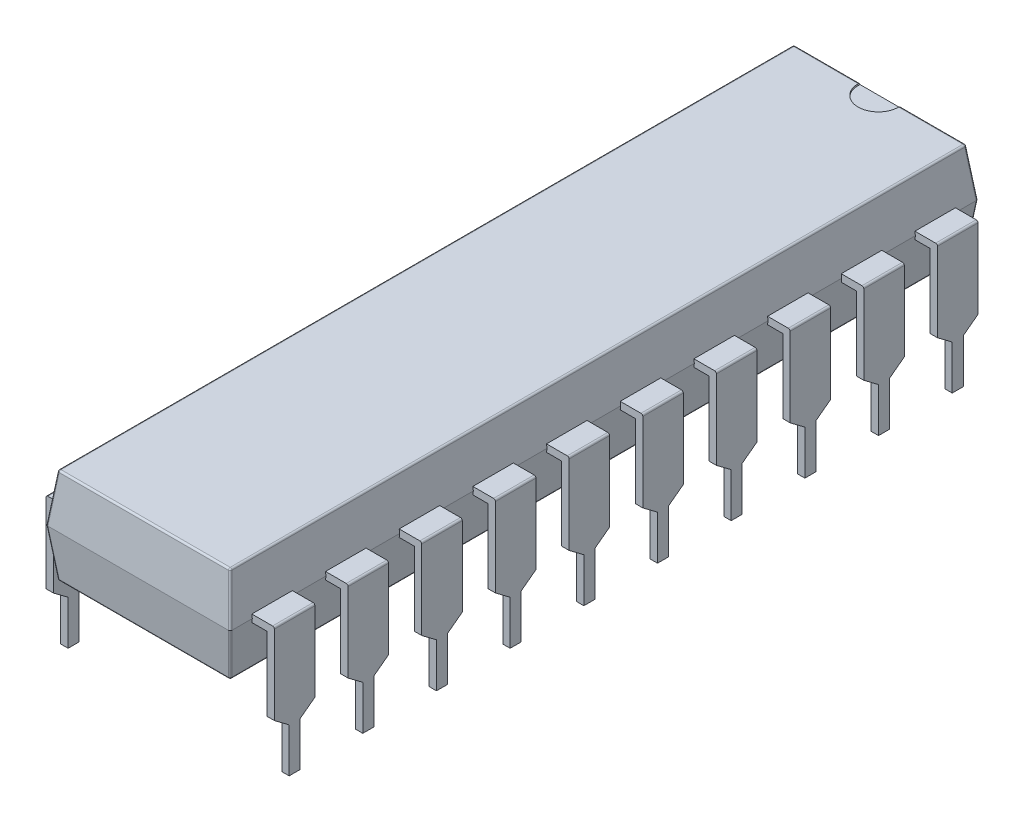
from build123d import *

# Parameters (mm, degrees)
SKETCH1_W                = 6.35
SKETCH1_H                = 25.781
EXTRUDE1_DEPTH           = 1.651
EXTRUDE1_TAPER           = 7
EXTRUDE1_OTHER_WAY_DEPTH = 1.651
EXTRUDE1_OTHER_WAY_TAPER = 7
SKETCH2_W                = 0.790734928
SKETCH2_H                = 1.397
EXTRUDE6_DEPTH           = 0.127
SKETCH7_W                = 0.254
SKETCH7_H                = 1.397
EXTRUDE7_DEPTH           = 4.699
FILLET2_R                = 0.0635
SKETCH6_R                = 0.6985
CUT_EXTRUDE2_DEPTH       = 0.05576
CUT_EXTRUDE3_DEPTH       = 16.415859469
LPATTERN8_COUNT          = 5
LPATTERN8_PITCH          = 2.54
LPATTERN8_COUNT_DIR2     = 6
LPATTERN8_PITCH_DIR2     = 2.54
FILLET6_R                = 0.0635
MIRROR1_COPY_1_SKETCH_W  = 0.790734928
MIRROR1_COPY_1_SKETCH_H  = 1.397
MIRROR1_COPY_1_DEPTH     = 0.127
MIRROR1_COPY_2_SKETCH_W  = 0.790734928
MIRROR1_COPY_2_SKETCH_H  = 1.397
MIRROR1_COPY_2_DEPTH     = 0.127
MIRROR1_COPY_3_SKETCH_W  = 0.790734928
MIRROR1_COPY_3_SKETCH_H  = 1.397
MIRROR1_COPY_3_DEPTH     = 0.127
MIRROR1_COPY_4_SKETCH_W  = 0.790734928
MIRROR1_COPY_4_SKETCH_H  = 1.397
MIRROR1_COPY_4_DEPTH     = 0.127
MIRROR1_COPY_5_SKETCH_W  = 0.790734928
MIRROR1_COPY_5_SKETCH_H  = 1.397
MIRROR1_COPY_5_DEPTH     = 0.127
MIRROR1_COPY_6_SKETCH_W  = 0.790734928
MIRROR1_COPY_6_SKETCH_H  = 1.397
MIRROR1_COPY_6_DEPTH     = 0.127
MIRROR1_COPY_7_SKETCH_W  = 0.790734928
MIRROR1_COPY_7_SKETCH_H  = 1.397
MIRROR1_COPY_7_DEPTH     = 0.127
MIRROR1_COPY_8_SKETCH_W  = 0.790734928
MIRROR1_COPY_8_SKETCH_H  = 1.397
MIRROR1_COPY_8_DEPTH     = 0.127
MIRROR1_COPY_9_SKETCH_W  = 0.790734928
MIRROR1_COPY_9_SKETCH_H  = 1.397
MIRROR1_COPY_9_DEPTH     = 0.127
MIRROR1_COPY_10_SKETCH_W = 0.790734928
MIRROR1_COPY_10_SKETCH_H = 1.397
MIRROR1_COPY_10_DEPTH    = 0.127
MIRROR1_COPY_11_SKETCH_W = 0.790734928
MIRROR1_COPY_11_SKETCH_H = 1.397
MIRROR1_COPY_11_DEPTH    = 0.127
MIRROR1_COPY_12_SKETCH_W = 0.790734928
MIRROR1_COPY_12_SKETCH_H = 1.397
MIRROR1_COPY_12_DEPTH    = 0.127
MIRROR1_COPY_13_SKETCH_W = 0.790734928
MIRROR1_COPY_13_SKETCH_H = 1.397
MIRROR1_COPY_13_DEPTH    = 0.127
MIRROR1_COPY_14_SKETCH_W = 0.790734928
MIRROR1_COPY_14_SKETCH_H = 1.397
MIRROR1_COPY_14_DEPTH    = 0.127
MIRROR1_COPY_15_SKETCH_W = 0.790734928
MIRROR1_COPY_15_SKETCH_H = 1.397
MIRROR1_COPY_15_DEPTH    = 0.127
MIRROR1_COPY_16_SKETCH_W = 0.790734928
MIRROR1_COPY_16_SKETCH_H = 1.397
MIRROR1_COPY_16_DEPTH    = 0.127
MIRROR1_COPY_17_SKETCH_W = 0.790734928
MIRROR1_COPY_17_SKETCH_H = 1.397
MIRROR1_COPY_17_DEPTH    = 0.127
MIRROR1_COPY_18_SKETCH_W = 0.790734928
MIRROR1_COPY_18_SKETCH_H = 1.397
MIRROR1_COPY_18_DEPTH    = 0.127
MIRROR1_COPY_19_SKETCH_W = 0.790734928
MIRROR1_COPY_19_SKETCH_H = 1.397
MIRROR1_COPY_19_DEPTH    = 0.127
MIRROR1_COPY_20_SKETCH_W = 0.790734928
MIRROR1_COPY_20_SKETCH_H = 1.397
MIRROR1_COPY_20_DEPTH    = 0.127
MIRROR1_COPY_21_SKETCH_W = 0.790734928
MIRROR1_COPY_21_SKETCH_H = 1.397
MIRROR1_COPY_21_DEPTH    = 0.127
MIRROR1_COPY_22_SKETCH_W = 0.790734928
MIRROR1_COPY_22_SKETCH_H = 1.397
MIRROR1_COPY_22_DEPTH    = 0.127
MIRROR1_COPY_23_SKETCH_W = 0.790734928
MIRROR1_COPY_23_SKETCH_H = 1.397
MIRROR1_COPY_23_DEPTH    = 0.127
MIRROR1_COPY_24_SKETCH_W = 0.790734928
MIRROR1_COPY_24_SKETCH_H = 1.397
MIRROR1_COPY_24_DEPTH    = 0.127
MIRROR1_COPY_25_SKETCH_W = 0.790734928
MIRROR1_COPY_25_SKETCH_H = 1.397
MIRROR1_COPY_25_DEPTH    = 0.127
MIRROR1_COPY_26_SKETCH_W = 0.790734928
MIRROR1_COPY_26_SKETCH_H = 1.397
MIRROR1_COPY_26_DEPTH    = 0.127
MIRROR1_COPY_27_SKETCH_W = 0.790734928
MIRROR1_COPY_27_SKETCH_H = 1.397
MIRROR1_COPY_27_DEPTH    = 0.127
MIRROR1_COPY_28_SKETCH_W = 0.790734928
MIRROR1_COPY_28_SKETCH_H = 1.397
MIRROR1_COPY_28_DEPTH    = 0.127
MIRROR1_COPY_29_SKETCH_W = 0.790734928
MIRROR1_COPY_29_SKETCH_H = 1.397
MIRROR1_COPY_29_DEPTH    = 0.127
MIRROR1_COPY_30_SKETCH_W = 0.254
MIRROR1_COPY_30_SKETCH_H = 1.397
MIRROR1_COPY_30_DEPTH    = 4.699
MIRROR1_COPY_31_SKETCH_W = 0.254
MIRROR1_COPY_31_SKETCH_H = 1.397
MIRROR1_COPY_31_DEPTH    = 4.699
MIRROR1_COPY_32_SKETCH_W = 0.254
MIRROR1_COPY_32_SKETCH_H = 1.397
MIRROR1_COPY_32_DEPTH    = 4.699
MIRROR1_COPY_33_SKETCH_W = 0.254
MIRROR1_COPY_33_SKETCH_H = 1.397
MIRROR1_COPY_33_DEPTH    = 4.699
MIRROR1_COPY_34_SKETCH_W = 0.254
MIRROR1_COPY_34_SKETCH_H = 1.397
MIRROR1_COPY_34_DEPTH    = 4.699
MIRROR1_COPY_35_SKETCH_W = 0.254
MIRROR1_COPY_35_SKETCH_H = 1.397
MIRROR1_COPY_35_DEPTH    = 4.699
MIRROR1_COPY_36_SKETCH_W = 0.254
MIRROR1_COPY_36_SKETCH_H = 1.397
MIRROR1_COPY_36_DEPTH    = 4.699
MIRROR1_COPY_37_SKETCH_W = 0.254
MIRROR1_COPY_37_SKETCH_H = 1.397
MIRROR1_COPY_37_DEPTH    = 4.699
MIRROR1_COPY_38_SKETCH_W = 0.254
MIRROR1_COPY_38_SKETCH_H = 1.397
MIRROR1_COPY_38_DEPTH    = 4.699
MIRROR1_COPY_39_SKETCH_W = 0.254
MIRROR1_COPY_39_SKETCH_H = 1.397
MIRROR1_COPY_39_DEPTH    = 4.699
MIRROR1_COPY_40_SKETCH_W = 0.254
MIRROR1_COPY_40_SKETCH_H = 1.397
MIRROR1_COPY_40_DEPTH    = 4.699
MIRROR1_COPY_41_SKETCH_W = 0.254
MIRROR1_COPY_41_SKETCH_H = 1.397
MIRROR1_COPY_41_DEPTH    = 4.699
MIRROR1_COPY_42_SKETCH_W = 0.254
MIRROR1_COPY_42_SKETCH_H = 1.397
MIRROR1_COPY_42_DEPTH    = 4.699
MIRROR1_COPY_43_SKETCH_W = 0.254
MIRROR1_COPY_43_SKETCH_H = 1.397
MIRROR1_COPY_43_DEPTH    = 4.699
MIRROR1_COPY_44_SKETCH_W = 0.254
MIRROR1_COPY_44_SKETCH_H = 1.397
MIRROR1_COPY_44_DEPTH    = 4.699
MIRROR1_COPY_45_SKETCH_W = 0.254
MIRROR1_COPY_45_SKETCH_H = 1.397
MIRROR1_COPY_45_DEPTH    = 4.699
MIRROR1_COPY_46_SKETCH_W = 0.254
MIRROR1_COPY_46_SKETCH_H = 1.397
MIRROR1_COPY_46_DEPTH    = 4.699
MIRROR1_COPY_47_SKETCH_W = 0.254
MIRROR1_COPY_47_SKETCH_H = 1.397
MIRROR1_COPY_47_DEPTH    = 4.699
MIRROR1_COPY_48_SKETCH_W = 0.254
MIRROR1_COPY_48_SKETCH_H = 1.397
MIRROR1_COPY_48_DEPTH    = 4.699
MIRROR1_COPY_49_SKETCH_W = 0.254
MIRROR1_COPY_49_SKETCH_H = 1.397
MIRROR1_COPY_49_DEPTH    = 4.699
MIRROR1_COPY_50_SKETCH_W = 0.254
MIRROR1_COPY_50_SKETCH_H = 1.397
MIRROR1_COPY_50_DEPTH    = 4.699
MIRROR1_COPY_51_SKETCH_W = 0.254
MIRROR1_COPY_51_SKETCH_H = 1.397
MIRROR1_COPY_51_DEPTH    = 4.699
MIRROR1_COPY_52_SKETCH_W = 0.254
MIRROR1_COPY_52_SKETCH_H = 1.397
MIRROR1_COPY_52_DEPTH    = 4.699
MIRROR1_COPY_53_SKETCH_W = 0.254
MIRROR1_COPY_53_SKETCH_H = 1.397
MIRROR1_COPY_53_DEPTH    = 4.699
MIRROR1_COPY_54_SKETCH_W = 0.254
MIRROR1_COPY_54_SKETCH_H = 1.397
MIRROR1_COPY_54_DEPTH    = 4.699
MIRROR1_COPY_55_SKETCH_W = 0.254
MIRROR1_COPY_55_SKETCH_H = 1.397
MIRROR1_COPY_55_DEPTH    = 4.699
MIRROR1_COPY_56_SKETCH_W = 0.254
MIRROR1_COPY_56_SKETCH_H = 1.397
MIRROR1_COPY_56_DEPTH    = 4.699
MIRROR1_COPY_57_SKETCH_W = 0.254
MIRROR1_COPY_57_SKETCH_H = 1.397
MIRROR1_COPY_57_DEPTH    = 4.699
MIRROR1_COPY_58_SKETCH_W = 0.254
MIRROR1_COPY_58_SKETCH_H = 1.397
MIRROR1_COPY_58_DEPTH    = 4.699
MIRROR1_COPY_59_DEPTH    = 16.415859469
MIRROR1_COPY_60_DEPTH    = 16.415859469
MIRROR1_COPY_61_DEPTH    = 16.415859469
MIRROR1_COPY_62_DEPTH    = 16.415859469
MIRROR1_COPY_63_DEPTH    = 16.415859469
MIRROR1_COPY_64_DEPTH    = 16.415859469
MIRROR1_COPY_65_DEPTH    = 16.415859469
MIRROR1_COPY_66_DEPTH    = 16.415859469
MIRROR1_COPY_67_DEPTH    = 16.415859469
MIRROR1_COPY_68_DEPTH    = 16.415859469
MIRROR1_COPY_69_DEPTH    = 16.415859469
MIRROR1_COPY_70_DEPTH    = 16.415859469
MIRROR1_COPY_71_DEPTH    = 16.415859469
MIRROR1_COPY_72_DEPTH    = 16.415859469
MIRROR1_COPY_73_DEPTH    = 16.415859469
MIRROR1_COPY_74_DEPTH    = 16.415859469
MIRROR1_COPY_75_DEPTH    = 16.415859469
MIRROR1_COPY_76_DEPTH    = 16.415859469
MIRROR1_COPY_77_DEPTH    = 16.415859469
MIRROR1_COPY_78_DEPTH    = 16.415859469
MIRROR1_COPY_79_DEPTH    = 16.415859469
MIRROR1_COPY_80_DEPTH    = 16.415859469
MIRROR1_COPY_81_DEPTH    = 16.415859469
MIRROR1_COPY_82_DEPTH    = 16.415859469
MIRROR1_COPY_83_DEPTH    = 16.415859469
MIRROR1_COPY_84_DEPTH    = 16.415859469
MIRROR1_COPY_85_DEPTH    = 16.415859469
MIRROR1_COPY_86_DEPTH    = 16.415859469
MIRROR1_COPY_87_DEPTH    = 16.415859469
FILLET7_R                = 0.0635


with BuildPart() as part:
    # Sketch1 → Extrude1 (new body)
    with BuildSketch(Plane(origin=(0, 0, 0), x_dir=(1, 0, 0), z_dir=(0, 1, 0))):
        Rectangle(SKETCH1_W, SKETCH1_H)
    extrude(amount=EXTRUDE1_DEPTH, taper=EXTRUDE1_TAPER)

    # Sketch1 → Extrude1 other way (add)
    with BuildSketch(Plane(origin=(0, 0, 0), x_dir=(1, 0, 0), z_dir=(0, 1, 0))):
        Rectangle(SKETCH1_W, SKETCH1_H)
    extrude(amount=-EXTRUDE1_OTHER_WAY_DEPTH, taper=EXTRUDE1_OTHER_WAY_TAPER)

    # Sketch2 → Extrude6 (add, symmetric)
    with BuildSketch(Plane(origin=(0, 0, 0), x_dir=(1, 0, 0), z_dir=(0, 1, 0))):
        with Locations((-3.541632536, -1.27)):
            Rectangle(SKETCH2_W, SKETCH2_H)
    extrude6 = extrude(amount=EXTRUDE6_DEPTH, both=True)

    # Sketch7 → Extrude7 (add)
    with BuildSketch(Plane(origin=(0, 0.127, 0), x_dir=(1, 0, 0), z_dir=(0, 1, 0))):
        with Locations((-3.81, -1.27)):
            Rectangle(SKETCH7_W, SKETCH7_H)
    extrude7 = extrude(amount=-EXTRUDE7_DEPTH)

    # Fillet2
    fillet2_edges = [part.edges().sort_by_distance(p)[0] for p in [
        (2.97228269, -1.651, 0),
        (0, -1.651, -12.68778269),
        (-3.073641345, 0.8255, -12.789141345),
        (-3.073641345, 0.8255, 12.789141345),
        (3.073641345, 0.8255, 12.789141345),
        (3.073641345, 0.8255, -12.789141345),
        (-2.97228269, 1.651, 0),
        (0, 1.651, 12.68778269),
        (2.97228269, 1.651, 0),
        (0, 1.651, -12.68778269),
        (-2.97228269, -1.651, 0),
        (0, -1.651, 12.68778269),
        (-3.073641345, -0.8255, -12.789141345),
        (3.073641345, -0.8255, -12.789141345),
        (3.073641345, -0.8255, 12.789141345),
        (-3.073641345, -0.8255, 12.789141345),
    ]]
    fillet(fillet2_edges, radius=FILLET2_R)

    # Sketch6 → Cut-Extrude2 (cut)
    with BuildSketch(Plane(origin=(0, 1.651, 0), x_dir=(1, 0, 0), z_dir=(0, 1, 0))):
        with Locations((0, 12.631602636)):
            Circle(SKETCH6_R)
    extrude(amount=-CUT_EXTRUDE2_DEPTH, mode=Mode.SUBTRACT)

    # Sketch8 → Cut-Extrude3 (cut, through all)
    with BuildSketch(Plane.ZY.offset(3.937)):
        Polygon((1.4605, -4.668977996), (1.4605, -3.048), (1.9685, -2.667), (2.56921373, -2.667), (2.56921373, -4.668977996), align=None)
        Polygon((-0.02921373, -4.668977996), (1.0795, -4.668977996), (1.0795, -3.048), (0.5715, -2.667), (-0.02921373, -2.667), align=None)
    cut_extrude3 = extrude(amount=-CUT_EXTRUDE3_DEPTH, mode=Mode.SUBTRACT)

    # LPattern8: Extrude6, Extrude7, Cut-Extrude3 5 × 6
    with Locations(*[Vector(0, 0, 1) * (i * LPATTERN8_PITCH) + Vector(0, 0, -1) * (j * LPATTERN8_PITCH_DIR2) for i in range(LPATTERN8_COUNT) for j in range(LPATTERN8_COUNT_DIR2) if (i, j) != (0, 0)]):
        add(extrude6)
        add(extrude7)
        add(cut_extrude3, mode=Mode.SUBTRACT)

    # Fillet6
    fillet6_edges = [part.edges().sort_by_distance(p)[0] for p in [
        (-3.937, 0.127, -1.27),
        (-3.937, 0.127, -3.81),
        (-3.937, 0.127, -6.35),
        (-3.937, 0.127, -8.89),
        (-3.937, 0.127, -11.43),
        (-3.937, 0.127, 3.81),
        (-3.937, 0.127, 6.35),
        (-3.937, 0.127, 8.89),
        (-3.937, 0.127, 1.27),
        (-3.937, 0.127, 11.43),
    ]]
    fillet(fillet6_edges, radius=FILLET6_R)

    # Mirror1: Extrude6, Extrude7, Cut-Extrude3 across plane
    add(extrude6.mirror(Plane(origin=(0, 0, 0), x_dir=(0, 0, 1), z_dir=(1, 0, 0))))
    add(extrude7.mirror(Plane(origin=(0, 0, 0), x_dir=(0, 0, 1), z_dir=(1, 0, 0))))
    add(cut_extrude3.mirror(Plane(origin=(0, 0, 0), x_dir=(0, 0, 1), z_dir=(1, 0, 0))), mode=Mode.SUBTRACT)

    # Mirror1 copy 1 sketch → Mirror1 copy 1 (add, symmetric)
    with BuildSketch(Plane(origin=(0, 0, -2.54), x_dir=(-1, 0, 0), z_dir=(0, 1, 0))):
        with Locations((-3.541632536, 1.27)):
            Rectangle(MIRROR1_COPY_1_SKETCH_W, MIRROR1_COPY_1_SKETCH_H)
    extrude(amount=MIRROR1_COPY_1_DEPTH, both=True)

    # Mirror1 copy 2 sketch → Mirror1 copy 2 (add, symmetric)
    with BuildSketch(Plane(origin=(0, 0, -5.08), x_dir=(-1, 0, 0), z_dir=(0, 1, 0))):
        with Locations((-3.541632536, 1.27)):
            Rectangle(MIRROR1_COPY_2_SKETCH_W, MIRROR1_COPY_2_SKETCH_H)
    extrude(amount=MIRROR1_COPY_2_DEPTH, both=True)

    # Mirror1 copy 3 sketch → Mirror1 copy 3 (add, symmetric)
    with BuildSketch(Plane(origin=(0, 0, -7.62), x_dir=(-1, 0, 0), z_dir=(0, 1, 0))):
        with Locations((-3.541632536, 1.27)):
            Rectangle(MIRROR1_COPY_3_SKETCH_W, MIRROR1_COPY_3_SKETCH_H)
    extrude(amount=MIRROR1_COPY_3_DEPTH, both=True)

    # Mirror1 copy 4 sketch → Mirror1 copy 4 (add, symmetric)
    with BuildSketch(Plane(origin=(0, 0, -10.16), x_dir=(-1, 0, 0), z_dir=(0, 1, 0))):
        with Locations((-3.541632536, 1.27)):
            Rectangle(MIRROR1_COPY_4_SKETCH_W, MIRROR1_COPY_4_SKETCH_H)
    extrude(amount=MIRROR1_COPY_4_DEPTH, both=True)

    # Mirror1 copy 5 sketch → Mirror1 copy 5 (add, symmetric)
    with BuildSketch(Plane(origin=(0, 0, -12.7), x_dir=(-1, 0, 0), z_dir=(0, 1, 0))):
        with Locations((-3.541632536, 1.27)):
            Rectangle(MIRROR1_COPY_5_SKETCH_W, MIRROR1_COPY_5_SKETCH_H)
    extrude(amount=MIRROR1_COPY_5_DEPTH, both=True)

    # Mirror1 copy 6 sketch → Mirror1 copy 6 (add, symmetric)
    with BuildSketch(Plane(origin=(0, 0, 2.54), x_dir=(-1, 0, 0), z_dir=(0, 1, 0))):
        with Locations((-3.541632536, 1.27)):
            Rectangle(MIRROR1_COPY_6_SKETCH_W, MIRROR1_COPY_6_SKETCH_H)
    extrude(amount=MIRROR1_COPY_6_DEPTH, both=True)

    # Mirror1 copy 7 sketch → Mirror1 copy 7 (add, symmetric)
    with BuildSketch(Plane(origin=(0, 0, 0), x_dir=(-1, 0, 0), z_dir=(0, 1, 0))):
        with Locations((-3.541632536, 1.27)):
            Rectangle(MIRROR1_COPY_7_SKETCH_W, MIRROR1_COPY_7_SKETCH_H)
    extrude(amount=MIRROR1_COPY_7_DEPTH, both=True)

    # Mirror1 copy 8 sketch → Mirror1 copy 8 (add, symmetric)
    with BuildSketch(Plane(origin=(0, 0, -2.54), x_dir=(-1, 0, 0), z_dir=(0, 1, 0))):
        with Locations((-3.541632536, 1.27)):
            Rectangle(MIRROR1_COPY_8_SKETCH_W, MIRROR1_COPY_8_SKETCH_H)
    extrude(amount=MIRROR1_COPY_8_DEPTH, both=True)

    # Mirror1 copy 9 sketch → Mirror1 copy 9 (add, symmetric)
    with BuildSketch(Plane(origin=(0, 0, -5.08), x_dir=(-1, 0, 0), z_dir=(0, 1, 0))):
        with Locations((-3.541632536, 1.27)):
            Rectangle(MIRROR1_COPY_9_SKETCH_W, MIRROR1_COPY_9_SKETCH_H)
    extrude(amount=MIRROR1_COPY_9_DEPTH, both=True)

    # Mirror1 copy 10 sketch → Mirror1 copy 10 (add, symmetric)
    with BuildSketch(Plane(origin=(0, 0, -7.62), x_dir=(-1, 0, 0), z_dir=(0, 1, 0))):
        with Locations((-3.541632536, 1.27)):
            Rectangle(MIRROR1_COPY_10_SKETCH_W, MIRROR1_COPY_10_SKETCH_H)
    extrude(amount=MIRROR1_COPY_10_DEPTH, both=True)

    # Mirror1 copy 11 sketch → Mirror1 copy 11 (add, symmetric)
    with BuildSketch(Plane(origin=(0, 0, -10.16), x_dir=(-1, 0, 0), z_dir=(0, 1, 0))):
        with Locations((-3.541632536, 1.27)):
            Rectangle(MIRROR1_COPY_11_SKETCH_W, MIRROR1_COPY_11_SKETCH_H)
    extrude(amount=MIRROR1_COPY_11_DEPTH, both=True)

    # Mirror1 copy 12 sketch → Mirror1 copy 12 (add, symmetric)
    with BuildSketch(Plane(origin=(0, 0, 5.08), x_dir=(-1, 0, 0), z_dir=(0, 1, 0))):
        with Locations((-3.541632536, 1.27)):
            Rectangle(MIRROR1_COPY_12_SKETCH_W, MIRROR1_COPY_12_SKETCH_H)
    extrude(amount=MIRROR1_COPY_12_DEPTH, both=True)

    # Mirror1 copy 13 sketch → Mirror1 copy 13 (add, symmetric)
    with BuildSketch(Plane(origin=(0, 0, 2.54), x_dir=(-1, 0, 0), z_dir=(0, 1, 0))):
        with Locations((-3.541632536, 1.27)):
            Rectangle(MIRROR1_COPY_13_SKETCH_W, MIRROR1_COPY_13_SKETCH_H)
    extrude(amount=MIRROR1_COPY_13_DEPTH, both=True)

    # Mirror1 copy 14 sketch → Mirror1 copy 14 (add, symmetric)
    with BuildSketch(Plane(origin=(0, 0, 0), x_dir=(-1, 0, 0), z_dir=(0, 1, 0))):
        with Locations((-3.541632536, 1.27)):
            Rectangle(MIRROR1_COPY_14_SKETCH_W, MIRROR1_COPY_14_SKETCH_H)
    extrude(amount=MIRROR1_COPY_14_DEPTH, both=True)

    # Mirror1 copy 15 sketch → Mirror1 copy 15 (add, symmetric)
    with BuildSketch(Plane(origin=(0, 0, -2.54), x_dir=(-1, 0, 0), z_dir=(0, 1, 0))):
        with Locations((-3.541632536, 1.27)):
            Rectangle(MIRROR1_COPY_15_SKETCH_W, MIRROR1_COPY_15_SKETCH_H)
    extrude(amount=MIRROR1_COPY_15_DEPTH, both=True)

    # Mirror1 copy 16 sketch → Mirror1 copy 16 (add, symmetric)
    with BuildSketch(Plane(origin=(0, 0, -5.08), x_dir=(-1, 0, 0), z_dir=(0, 1, 0))):
        with Locations((-3.541632536, 1.27)):
            Rectangle(MIRROR1_COPY_16_SKETCH_W, MIRROR1_COPY_16_SKETCH_H)
    extrude(amount=MIRROR1_COPY_16_DEPTH, both=True)

    # Mirror1 copy 17 sketch → Mirror1 copy 17 (add, symmetric)
    with BuildSketch(Plane(origin=(0, 0, -7.62), x_dir=(-1, 0, 0), z_dir=(0, 1, 0))):
        with Locations((-3.541632536, 1.27)):
            Rectangle(MIRROR1_COPY_17_SKETCH_W, MIRROR1_COPY_17_SKETCH_H)
    extrude(amount=MIRROR1_COPY_17_DEPTH, both=True)

    # Mirror1 copy 18 sketch → Mirror1 copy 18 (add, symmetric)
    with BuildSketch(Plane(origin=(0, 0, 7.62), x_dir=(-1, 0, 0), z_dir=(0, 1, 0))):
        with Locations((-3.541632536, 1.27)):
            Rectangle(MIRROR1_COPY_18_SKETCH_W, MIRROR1_COPY_18_SKETCH_H)
    extrude(amount=MIRROR1_COPY_18_DEPTH, both=True)

    # Mirror1 copy 19 sketch → Mirror1 copy 19 (add, symmetric)
    with BuildSketch(Plane(origin=(0, 0, 5.08), x_dir=(-1, 0, 0), z_dir=(0, 1, 0))):
        with Locations((-3.541632536, 1.27)):
            Rectangle(MIRROR1_COPY_19_SKETCH_W, MIRROR1_COPY_19_SKETCH_H)
    extrude(amount=MIRROR1_COPY_19_DEPTH, both=True)

    # Mirror1 copy 20 sketch → Mirror1 copy 20 (add, symmetric)
    with BuildSketch(Plane(origin=(0, 0, 2.54), x_dir=(-1, 0, 0), z_dir=(0, 1, 0))):
        with Locations((-3.541632536, 1.27)):
            Rectangle(MIRROR1_COPY_20_SKETCH_W, MIRROR1_COPY_20_SKETCH_H)
    extrude(amount=MIRROR1_COPY_20_DEPTH, both=True)

    # Mirror1 copy 21 sketch → Mirror1 copy 21 (add, symmetric)
    with BuildSketch(Plane(origin=(0, 0, 0), x_dir=(-1, 0, 0), z_dir=(0, 1, 0))):
        with Locations((-3.541632536, 1.27)):
            Rectangle(MIRROR1_COPY_21_SKETCH_W, MIRROR1_COPY_21_SKETCH_H)
    extrude(amount=MIRROR1_COPY_21_DEPTH, both=True)

    # Mirror1 copy 22 sketch → Mirror1 copy 22 (add, symmetric)
    with BuildSketch(Plane(origin=(0, 0, -2.54), x_dir=(-1, 0, 0), z_dir=(0, 1, 0))):
        with Locations((-3.541632536, 1.27)):
            Rectangle(MIRROR1_COPY_22_SKETCH_W, MIRROR1_COPY_22_SKETCH_H)
    extrude(amount=MIRROR1_COPY_22_DEPTH, both=True)

    # Mirror1 copy 23 sketch → Mirror1 copy 23 (add, symmetric)
    with BuildSketch(Plane(origin=(0, 0, -5.08), x_dir=(-1, 0, 0), z_dir=(0, 1, 0))):
        with Locations((-3.541632536, 1.27)):
            Rectangle(MIRROR1_COPY_23_SKETCH_W, MIRROR1_COPY_23_SKETCH_H)
    extrude(amount=MIRROR1_COPY_23_DEPTH, both=True)

    # Mirror1 copy 24 sketch → Mirror1 copy 24 (add, symmetric)
    with BuildSketch(Plane(origin=(0, 0, 10.16), x_dir=(-1, 0, 0), z_dir=(0, 1, 0))):
        with Locations((-3.541632536, 1.27)):
            Rectangle(MIRROR1_COPY_24_SKETCH_W, MIRROR1_COPY_24_SKETCH_H)
    extrude(amount=MIRROR1_COPY_24_DEPTH, both=True)

    # Mirror1 copy 25 sketch → Mirror1 copy 25 (add, symmetric)
    with BuildSketch(Plane(origin=(0, 0, 7.62), x_dir=(-1, 0, 0), z_dir=(0, 1, 0))):
        with Locations((-3.541632536, 1.27)):
            Rectangle(MIRROR1_COPY_25_SKETCH_W, MIRROR1_COPY_25_SKETCH_H)
    extrude(amount=MIRROR1_COPY_25_DEPTH, both=True)

    # Mirror1 copy 26 sketch → Mirror1 copy 26 (add, symmetric)
    with BuildSketch(Plane(origin=(0, 0, 5.08), x_dir=(-1, 0, 0), z_dir=(0, 1, 0))):
        with Locations((-3.541632536, 1.27)):
            Rectangle(MIRROR1_COPY_26_SKETCH_W, MIRROR1_COPY_26_SKETCH_H)
    extrude(amount=MIRROR1_COPY_26_DEPTH, both=True)

    # Mirror1 copy 27 sketch → Mirror1 copy 27 (add, symmetric)
    with BuildSketch(Plane(origin=(0, 0, 2.54), x_dir=(-1, 0, 0), z_dir=(0, 1, 0))):
        with Locations((-3.541632536, 1.27)):
            Rectangle(MIRROR1_COPY_27_SKETCH_W, MIRROR1_COPY_27_SKETCH_H)
    extrude(amount=MIRROR1_COPY_27_DEPTH, both=True)

    # Mirror1 copy 28 sketch → Mirror1 copy 28 (add, symmetric)
    with BuildSketch(Plane(origin=(0, 0, 0), x_dir=(-1, 0, 0), z_dir=(0, 1, 0))):
        with Locations((-3.541632536, 1.27)):
            Rectangle(MIRROR1_COPY_28_SKETCH_W, MIRROR1_COPY_28_SKETCH_H)
    extrude(amount=MIRROR1_COPY_28_DEPTH, both=True)

    # Mirror1 copy 29 sketch → Mirror1 copy 29 (add, symmetric)
    with BuildSketch(Plane(origin=(0, 0, -2.54), x_dir=(-1, 0, 0), z_dir=(0, 1, 0))):
        with Locations((-3.541632536, 1.27)):
            Rectangle(MIRROR1_COPY_29_SKETCH_W, MIRROR1_COPY_29_SKETCH_H)
    extrude(amount=MIRROR1_COPY_29_DEPTH, both=True)

    # Mirror1 copy 30 sketch → Mirror1 copy 30 (add)
    with BuildSketch(Plane(origin=(0, 0.127, -2.54), x_dir=(-1, 0, 0), z_dir=(0, 1, 0))):
        with Locations((-3.81, 1.27)):
            Rectangle(MIRROR1_COPY_30_SKETCH_W, MIRROR1_COPY_30_SKETCH_H)
    extrude(amount=-MIRROR1_COPY_30_DEPTH)

    # Mirror1 copy 31 sketch → Mirror1 copy 31 (add)
    with BuildSketch(Plane(origin=(0, 0.127, -5.08), x_dir=(-1, 0, 0), z_dir=(0, 1, 0))):
        with Locations((-3.81, 1.27)):
            Rectangle(MIRROR1_COPY_31_SKETCH_W, MIRROR1_COPY_31_SKETCH_H)
    extrude(amount=-MIRROR1_COPY_31_DEPTH)

    # Mirror1 copy 32 sketch → Mirror1 copy 32 (add)
    with BuildSketch(Plane(origin=(0, 0.127, -7.62), x_dir=(-1, 0, 0), z_dir=(0, 1, 0))):
        with Locations((-3.81, 1.27)):
            Rectangle(MIRROR1_COPY_32_SKETCH_W, MIRROR1_COPY_32_SKETCH_H)
    extrude(amount=-MIRROR1_COPY_32_DEPTH)

    # Mirror1 copy 33 sketch → Mirror1 copy 33 (add)
    with BuildSketch(Plane(origin=(0, 0.127, -10.16), x_dir=(-1, 0, 0), z_dir=(0, 1, 0))):
        with Locations((-3.81, 1.27)):
            Rectangle(MIRROR1_COPY_33_SKETCH_W, MIRROR1_COPY_33_SKETCH_H)
    extrude(amount=-MIRROR1_COPY_33_DEPTH)

    # Mirror1 copy 34 sketch → Mirror1 copy 34 (add)
    with BuildSketch(Plane(origin=(0, 0.127, -12.7), x_dir=(-1, 0, 0), z_dir=(0, 1, 0))):
        with Locations((-3.81, 1.27)):
            Rectangle(MIRROR1_COPY_34_SKETCH_W, MIRROR1_COPY_34_SKETCH_H)
    extrude(amount=-MIRROR1_COPY_34_DEPTH)

    # Mirror1 copy 35 sketch → Mirror1 copy 35 (add)
    with BuildSketch(Plane(origin=(0, 0.127, 2.54), x_dir=(-1, 0, 0), z_dir=(0, 1, 0))):
        with Locations((-3.81, 1.27)):
            Rectangle(MIRROR1_COPY_35_SKETCH_W, MIRROR1_COPY_35_SKETCH_H)
    extrude(amount=-MIRROR1_COPY_35_DEPTH)

    # Mirror1 copy 36 sketch → Mirror1 copy 36 (add)
    with BuildSketch(Plane(origin=(0, 0.127, 0), x_dir=(-1, 0, 0), z_dir=(0, 1, 0))):
        with Locations((-3.81, 1.27)):
            Rectangle(MIRROR1_COPY_36_SKETCH_W, MIRROR1_COPY_36_SKETCH_H)
    extrude(amount=-MIRROR1_COPY_36_DEPTH)

    # Mirror1 copy 37 sketch → Mirror1 copy 37 (add)
    with BuildSketch(Plane(origin=(0, 0.127, -2.54), x_dir=(-1, 0, 0), z_dir=(0, 1, 0))):
        with Locations((-3.81, 1.27)):
            Rectangle(MIRROR1_COPY_37_SKETCH_W, MIRROR1_COPY_37_SKETCH_H)
    extrude(amount=-MIRROR1_COPY_37_DEPTH)

    # Mirror1 copy 38 sketch → Mirror1 copy 38 (add)
    with BuildSketch(Plane(origin=(0, 0.127, -5.08), x_dir=(-1, 0, 0), z_dir=(0, 1, 0))):
        with Locations((-3.81, 1.27)):
            Rectangle(MIRROR1_COPY_38_SKETCH_W, MIRROR1_COPY_38_SKETCH_H)
    extrude(amount=-MIRROR1_COPY_38_DEPTH)

    # Mirror1 copy 39 sketch → Mirror1 copy 39 (add)
    with BuildSketch(Plane(origin=(0, 0.127, -7.62), x_dir=(-1, 0, 0), z_dir=(0, 1, 0))):
        with Locations((-3.81, 1.27)):
            Rectangle(MIRROR1_COPY_39_SKETCH_W, MIRROR1_COPY_39_SKETCH_H)
    extrude(amount=-MIRROR1_COPY_39_DEPTH)

    # Mirror1 copy 40 sketch → Mirror1 copy 40 (add)
    with BuildSketch(Plane(origin=(0, 0.127, -10.16), x_dir=(-1, 0, 0), z_dir=(0, 1, 0))):
        with Locations((-3.81, 1.27)):
            Rectangle(MIRROR1_COPY_40_SKETCH_W, MIRROR1_COPY_40_SKETCH_H)
    extrude(amount=-MIRROR1_COPY_40_DEPTH)

    # Mirror1 copy 41 sketch → Mirror1 copy 41 (add)
    with BuildSketch(Plane(origin=(0, 0.127, 5.08), x_dir=(-1, 0, 0), z_dir=(0, 1, 0))):
        with Locations((-3.81, 1.27)):
            Rectangle(MIRROR1_COPY_41_SKETCH_W, MIRROR1_COPY_41_SKETCH_H)
    extrude(amount=-MIRROR1_COPY_41_DEPTH)

    # Mirror1 copy 42 sketch → Mirror1 copy 42 (add)
    with BuildSketch(Plane(origin=(0, 0.127, 2.54), x_dir=(-1, 0, 0), z_dir=(0, 1, 0))):
        with Locations((-3.81, 1.27)):
            Rectangle(MIRROR1_COPY_42_SKETCH_W, MIRROR1_COPY_42_SKETCH_H)
    extrude(amount=-MIRROR1_COPY_42_DEPTH)

    # Mirror1 copy 43 sketch → Mirror1 copy 43 (add)
    with BuildSketch(Plane(origin=(0, 0.127, 0), x_dir=(-1, 0, 0), z_dir=(0, 1, 0))):
        with Locations((-3.81, 1.27)):
            Rectangle(MIRROR1_COPY_43_SKETCH_W, MIRROR1_COPY_43_SKETCH_H)
    extrude(amount=-MIRROR1_COPY_43_DEPTH)

    # Mirror1 copy 44 sketch → Mirror1 copy 44 (add)
    with BuildSketch(Plane(origin=(0, 0.127, -2.54), x_dir=(-1, 0, 0), z_dir=(0, 1, 0))):
        with Locations((-3.81, 1.27)):
            Rectangle(MIRROR1_COPY_44_SKETCH_W, MIRROR1_COPY_44_SKETCH_H)
    extrude(amount=-MIRROR1_COPY_44_DEPTH)

    # Mirror1 copy 45 sketch → Mirror1 copy 45 (add)
    with BuildSketch(Plane(origin=(0, 0.127, -5.08), x_dir=(-1, 0, 0), z_dir=(0, 1, 0))):
        with Locations((-3.81, 1.27)):
            Rectangle(MIRROR1_COPY_45_SKETCH_W, MIRROR1_COPY_45_SKETCH_H)
    extrude(amount=-MIRROR1_COPY_45_DEPTH)

    # Mirror1 copy 46 sketch → Mirror1 copy 46 (add)
    with BuildSketch(Plane(origin=(0, 0.127, -7.62), x_dir=(-1, 0, 0), z_dir=(0, 1, 0))):
        with Locations((-3.81, 1.27)):
            Rectangle(MIRROR1_COPY_46_SKETCH_W, MIRROR1_COPY_46_SKETCH_H)
    extrude(amount=-MIRROR1_COPY_46_DEPTH)

    # Mirror1 copy 47 sketch → Mirror1 copy 47 (add)
    with BuildSketch(Plane(origin=(0, 0.127, 7.62), x_dir=(-1, 0, 0), z_dir=(0, 1, 0))):
        with Locations((-3.81, 1.27)):
            Rectangle(MIRROR1_COPY_47_SKETCH_W, MIRROR1_COPY_47_SKETCH_H)
    extrude(amount=-MIRROR1_COPY_47_DEPTH)

    # Mirror1 copy 48 sketch → Mirror1 copy 48 (add)
    with BuildSketch(Plane(origin=(0, 0.127, 5.08), x_dir=(-1, 0, 0), z_dir=(0, 1, 0))):
        with Locations((-3.81, 1.27)):
            Rectangle(MIRROR1_COPY_48_SKETCH_W, MIRROR1_COPY_48_SKETCH_H)
    extrude(amount=-MIRROR1_COPY_48_DEPTH)

    # Mirror1 copy 49 sketch → Mirror1 copy 49 (add)
    with BuildSketch(Plane(origin=(0, 0.127, 2.54), x_dir=(-1, 0, 0), z_dir=(0, 1, 0))):
        with Locations((-3.81, 1.27)):
            Rectangle(MIRROR1_COPY_49_SKETCH_W, MIRROR1_COPY_49_SKETCH_H)
    extrude(amount=-MIRROR1_COPY_49_DEPTH)

    # Mirror1 copy 50 sketch → Mirror1 copy 50 (add)
    with BuildSketch(Plane(origin=(0, 0.127, 0), x_dir=(-1, 0, 0), z_dir=(0, 1, 0))):
        with Locations((-3.81, 1.27)):
            Rectangle(MIRROR1_COPY_50_SKETCH_W, MIRROR1_COPY_50_SKETCH_H)
    extrude(amount=-MIRROR1_COPY_50_DEPTH)

    # Mirror1 copy 51 sketch → Mirror1 copy 51 (add)
    with BuildSketch(Plane(origin=(0, 0.127, -2.54), x_dir=(-1, 0, 0), z_dir=(0, 1, 0))):
        with Locations((-3.81, 1.27)):
            Rectangle(MIRROR1_COPY_51_SKETCH_W, MIRROR1_COPY_51_SKETCH_H)
    extrude(amount=-MIRROR1_COPY_51_DEPTH)

    # Mirror1 copy 52 sketch → Mirror1 copy 52 (add)
    with BuildSketch(Plane(origin=(0, 0.127, -5.08), x_dir=(-1, 0, 0), z_dir=(0, 1, 0))):
        with Locations((-3.81, 1.27)):
            Rectangle(MIRROR1_COPY_52_SKETCH_W, MIRROR1_COPY_52_SKETCH_H)
    extrude(amount=-MIRROR1_COPY_52_DEPTH)

    # Mirror1 copy 53 sketch → Mirror1 copy 53 (add)
    with BuildSketch(Plane(origin=(0, 0.127, 10.16), x_dir=(-1, 0, 0), z_dir=(0, 1, 0))):
        with Locations((-3.81, 1.27)):
            Rectangle(MIRROR1_COPY_53_SKETCH_W, MIRROR1_COPY_53_SKETCH_H)
    extrude(amount=-MIRROR1_COPY_53_DEPTH)

    # Mirror1 copy 54 sketch → Mirror1 copy 54 (add)
    with BuildSketch(Plane(origin=(0, 0.127, 7.62), x_dir=(-1, 0, 0), z_dir=(0, 1, 0))):
        with Locations((-3.81, 1.27)):
            Rectangle(MIRROR1_COPY_54_SKETCH_W, MIRROR1_COPY_54_SKETCH_H)
    extrude(amount=-MIRROR1_COPY_54_DEPTH)

    # Mirror1 copy 55 sketch → Mirror1 copy 55 (add)
    with BuildSketch(Plane(origin=(0, 0.127, 5.08), x_dir=(-1, 0, 0), z_dir=(0, 1, 0))):
        with Locations((-3.81, 1.27)):
            Rectangle(MIRROR1_COPY_55_SKETCH_W, MIRROR1_COPY_55_SKETCH_H)
    extrude(amount=-MIRROR1_COPY_55_DEPTH)

    # Mirror1 copy 56 sketch → Mirror1 copy 56 (add)
    with BuildSketch(Plane(origin=(0, 0.127, 2.54), x_dir=(-1, 0, 0), z_dir=(0, 1, 0))):
        with Locations((-3.81, 1.27)):
            Rectangle(MIRROR1_COPY_56_SKETCH_W, MIRROR1_COPY_56_SKETCH_H)
    extrude(amount=-MIRROR1_COPY_56_DEPTH)

    # Mirror1 copy 57 sketch → Mirror1 copy 57 (add)
    with BuildSketch(Plane(origin=(0, 0.127, 0), x_dir=(-1, 0, 0), z_dir=(0, 1, 0))):
        with Locations((-3.81, 1.27)):
            Rectangle(MIRROR1_COPY_57_SKETCH_W, MIRROR1_COPY_57_SKETCH_H)
    extrude(amount=-MIRROR1_COPY_57_DEPTH)

    # Mirror1 copy 58 sketch → Mirror1 copy 58 (add)
    with BuildSketch(Plane(origin=(0, 0.127, -2.54), x_dir=(-1, 0, 0), z_dir=(0, 1, 0))):
        with Locations((-3.81, 1.27)):
            Rectangle(MIRROR1_COPY_58_SKETCH_W, MIRROR1_COPY_58_SKETCH_H)
    extrude(amount=-MIRROR1_COPY_58_DEPTH)

    # Mirror1 copy 59 sketch → Mirror1 copy 59 (cut, through all)
    with BuildSketch(Plane(origin=(3.937, 0, -2.54), x_dir=(0, 0, 1), z_dir=(1, 0, 0))):
        Polygon((1.4605, 4.668977996), (1.4605, 3.048), (1.9685, 2.667), (2.56921373, 2.667), (2.56921373, 4.668977996), align=None)
        Polygon((-0.02921373, 4.668977996), (1.0795, 4.668977996), (1.0795, 3.048), (0.5715, 2.667), (-0.02921373, 2.667), align=None)
    extrude(amount=-MIRROR1_COPY_59_DEPTH, mode=Mode.SUBTRACT)

    # Mirror1 copy 60 sketch → Mirror1 copy 60 (cut, through all)
    with BuildSketch(Plane(origin=(3.937, 0, -5.08), x_dir=(0, 0, 1), z_dir=(1, 0, 0))):
        Polygon((1.4605, 4.668977996), (1.4605, 3.048), (1.9685, 2.667), (2.56921373, 2.667), (2.56921373, 4.668977996), align=None)
        Polygon((-0.02921373, 4.668977996), (1.0795, 4.668977996), (1.0795, 3.048), (0.5715, 2.667), (-0.02921373, 2.667), align=None)
    extrude(amount=-MIRROR1_COPY_60_DEPTH, mode=Mode.SUBTRACT)

    # Mirror1 copy 61 sketch → Mirror1 copy 61 (cut, through all)
    with BuildSketch(Plane(origin=(3.937, 0, -7.62), x_dir=(0, 0, 1), z_dir=(1, 0, 0))):
        Polygon((1.4605, 4.668977996), (1.4605, 3.048), (1.9685, 2.667), (2.56921373, 2.667), (2.56921373, 4.668977996), align=None)
        Polygon((-0.02921373, 4.668977996), (1.0795, 4.668977996), (1.0795, 3.048), (0.5715, 2.667), (-0.02921373, 2.667), align=None)
    extrude(amount=-MIRROR1_COPY_61_DEPTH, mode=Mode.SUBTRACT)

    # Mirror1 copy 62 sketch → Mirror1 copy 62 (cut, through all)
    with BuildSketch(Plane(origin=(3.937, 0, -10.16), x_dir=(0, 0, 1), z_dir=(1, 0, 0))):
        Polygon((1.4605, 4.668977996), (1.4605, 3.048), (1.9685, 2.667), (2.56921373, 2.667), (2.56921373, 4.668977996), align=None)
        Polygon((-0.02921373, 4.668977996), (1.0795, 4.668977996), (1.0795, 3.048), (0.5715, 2.667), (-0.02921373, 2.667), align=None)
    extrude(amount=-MIRROR1_COPY_62_DEPTH, mode=Mode.SUBTRACT)

    # Mirror1 copy 63 sketch → Mirror1 copy 63 (cut, through all)
    with BuildSketch(Plane(origin=(3.937, 0, -12.7), x_dir=(0, 0, 1), z_dir=(1, 0, 0))):
        Polygon((1.4605, 4.668977996), (1.4605, 3.048), (1.9685, 2.667), (2.56921373, 2.667), (2.56921373, 4.668977996), align=None)
        Polygon((-0.02921373, 4.668977996), (1.0795, 4.668977996), (1.0795, 3.048), (0.5715, 2.667), (-0.02921373, 2.667), align=None)
    extrude(amount=-MIRROR1_COPY_63_DEPTH, mode=Mode.SUBTRACT)

    # Mirror1 copy 64 sketch → Mirror1 copy 64 (cut, through all)
    with BuildSketch(Plane(origin=(3.937, 0, 2.54), x_dir=(0, 0, 1), z_dir=(1, 0, 0))):
        Polygon((1.4605, 4.668977996), (1.4605, 3.048), (1.9685, 2.667), (2.56921373, 2.667), (2.56921373, 4.668977996), align=None)
        Polygon((-0.02921373, 4.668977996), (1.0795, 4.668977996), (1.0795, 3.048), (0.5715, 2.667), (-0.02921373, 2.667), align=None)
    extrude(amount=-MIRROR1_COPY_64_DEPTH, mode=Mode.SUBTRACT)

    # Mirror1 copy 65 sketch → Mirror1 copy 65 (cut, through all)
    with BuildSketch(Plane(origin=(3.937, 0, 0), x_dir=(0, 0, 1), z_dir=(1, 0, 0))):
        Polygon((1.4605, 4.668977996), (1.4605, 3.048), (1.9685, 2.667), (2.56921373, 2.667), (2.56921373, 4.668977996), align=None)
        Polygon((-0.02921373, 4.668977996), (1.0795, 4.668977996), (1.0795, 3.048), (0.5715, 2.667), (-0.02921373, 2.667), align=None)
    extrude(amount=-MIRROR1_COPY_65_DEPTH, mode=Mode.SUBTRACT)

    # Mirror1 copy 66 sketch → Mirror1 copy 66 (cut, through all)
    with BuildSketch(Plane(origin=(3.937, 0, -2.54), x_dir=(0, 0, 1), z_dir=(1, 0, 0))):
        Polygon((1.4605, 4.668977996), (1.4605, 3.048), (1.9685, 2.667), (2.56921373, 2.667), (2.56921373, 4.668977996), align=None)
        Polygon((-0.02921373, 4.668977996), (1.0795, 4.668977996), (1.0795, 3.048), (0.5715, 2.667), (-0.02921373, 2.667), align=None)
    extrude(amount=-MIRROR1_COPY_66_DEPTH, mode=Mode.SUBTRACT)

    # Mirror1 copy 67 sketch → Mirror1 copy 67 (cut, through all)
    with BuildSketch(Plane(origin=(3.937, 0, -5.08), x_dir=(0, 0, 1), z_dir=(1, 0, 0))):
        Polygon((1.4605, 4.668977996), (1.4605, 3.048), (1.9685, 2.667), (2.56921373, 2.667), (2.56921373, 4.668977996), align=None)
        Polygon((-0.02921373, 4.668977996), (1.0795, 4.668977996), (1.0795, 3.048), (0.5715, 2.667), (-0.02921373, 2.667), align=None)
    extrude(amount=-MIRROR1_COPY_67_DEPTH, mode=Mode.SUBTRACT)

    # Mirror1 copy 68 sketch → Mirror1 copy 68 (cut, through all)
    with BuildSketch(Plane(origin=(3.937, 0, -7.62), x_dir=(0, 0, 1), z_dir=(1, 0, 0))):
        Polygon((1.4605, 4.668977996), (1.4605, 3.048), (1.9685, 2.667), (2.56921373, 2.667), (2.56921373, 4.668977996), align=None)
        Polygon((-0.02921373, 4.668977996), (1.0795, 4.668977996), (1.0795, 3.048), (0.5715, 2.667), (-0.02921373, 2.667), align=None)
    extrude(amount=-MIRROR1_COPY_68_DEPTH, mode=Mode.SUBTRACT)

    # Mirror1 copy 69 sketch → Mirror1 copy 69 (cut, through all)
    with BuildSketch(Plane(origin=(3.937, 0, -10.16), x_dir=(0, 0, 1), z_dir=(1, 0, 0))):
        Polygon((1.4605, 4.668977996), (1.4605, 3.048), (1.9685, 2.667), (2.56921373, 2.667), (2.56921373, 4.668977996), align=None)
        Polygon((-0.02921373, 4.668977996), (1.0795, 4.668977996), (1.0795, 3.048), (0.5715, 2.667), (-0.02921373, 2.667), align=None)
    extrude(amount=-MIRROR1_COPY_69_DEPTH, mode=Mode.SUBTRACT)

    # Mirror1 copy 70 sketch → Mirror1 copy 70 (cut, through all)
    with BuildSketch(Plane(origin=(3.937, 0, 5.08), x_dir=(0, 0, 1), z_dir=(1, 0, 0))):
        Polygon((1.4605, 4.668977996), (1.4605, 3.048), (1.9685, 2.667), (2.56921373, 2.667), (2.56921373, 4.668977996), align=None)
        Polygon((-0.02921373, 4.668977996), (1.0795, 4.668977996), (1.0795, 3.048), (0.5715, 2.667), (-0.02921373, 2.667), align=None)
    extrude(amount=-MIRROR1_COPY_70_DEPTH, mode=Mode.SUBTRACT)

    # Mirror1 copy 71 sketch → Mirror1 copy 71 (cut, through all)
    with BuildSketch(Plane(origin=(3.937, 0, 2.54), x_dir=(0, 0, 1), z_dir=(1, 0, 0))):
        Polygon((1.4605, 4.668977996), (1.4605, 3.048), (1.9685, 2.667), (2.56921373, 2.667), (2.56921373, 4.668977996), align=None)
        Polygon((-0.02921373, 4.668977996), (1.0795, 4.668977996), (1.0795, 3.048), (0.5715, 2.667), (-0.02921373, 2.667), align=None)
    extrude(amount=-MIRROR1_COPY_71_DEPTH, mode=Mode.SUBTRACT)

    # Mirror1 copy 72 sketch → Mirror1 copy 72 (cut, through all)
    with BuildSketch(Plane(origin=(3.937, 0, 0), x_dir=(0, 0, 1), z_dir=(1, 0, 0))):
        Polygon((1.4605, 4.668977996), (1.4605, 3.048), (1.9685, 2.667), (2.56921373, 2.667), (2.56921373, 4.668977996), align=None)
        Polygon((-0.02921373, 4.668977996), (1.0795, 4.668977996), (1.0795, 3.048), (0.5715, 2.667), (-0.02921373, 2.667), align=None)
    extrude(amount=-MIRROR1_COPY_72_DEPTH, mode=Mode.SUBTRACT)

    # Mirror1 copy 73 sketch → Mirror1 copy 73 (cut, through all)
    with BuildSketch(Plane(origin=(3.937, 0, -2.54), x_dir=(0, 0, 1), z_dir=(1, 0, 0))):
        Polygon((1.4605, 4.668977996), (1.4605, 3.048), (1.9685, 2.667), (2.56921373, 2.667), (2.56921373, 4.668977996), align=None)
        Polygon((-0.02921373, 4.668977996), (1.0795, 4.668977996), (1.0795, 3.048), (0.5715, 2.667), (-0.02921373, 2.667), align=None)
    extrude(amount=-MIRROR1_COPY_73_DEPTH, mode=Mode.SUBTRACT)

    # Mirror1 copy 74 sketch → Mirror1 copy 74 (cut, through all)
    with BuildSketch(Plane(origin=(3.937, 0, -5.08), x_dir=(0, 0, 1), z_dir=(1, 0, 0))):
        Polygon((1.4605, 4.668977996), (1.4605, 3.048), (1.9685, 2.667), (2.56921373, 2.667), (2.56921373, 4.668977996), align=None)
        Polygon((-0.02921373, 4.668977996), (1.0795, 4.668977996), (1.0795, 3.048), (0.5715, 2.667), (-0.02921373, 2.667), align=None)
    extrude(amount=-MIRROR1_COPY_74_DEPTH, mode=Mode.SUBTRACT)

    # Mirror1 copy 75 sketch → Mirror1 copy 75 (cut, through all)
    with BuildSketch(Plane(origin=(3.937, 0, -7.62), x_dir=(0, 0, 1), z_dir=(1, 0, 0))):
        Polygon((1.4605, 4.668977996), (1.4605, 3.048), (1.9685, 2.667), (2.56921373, 2.667), (2.56921373, 4.668977996), align=None)
        Polygon((-0.02921373, 4.668977996), (1.0795, 4.668977996), (1.0795, 3.048), (0.5715, 2.667), (-0.02921373, 2.667), align=None)
    extrude(amount=-MIRROR1_COPY_75_DEPTH, mode=Mode.SUBTRACT)

    # Mirror1 copy 76 sketch → Mirror1 copy 76 (cut, through all)
    with BuildSketch(Plane(origin=(3.937, 0, 7.62), x_dir=(0, 0, 1), z_dir=(1, 0, 0))):
        Polygon((1.4605, 4.668977996), (1.4605, 3.048), (1.9685, 2.667), (2.56921373, 2.667), (2.56921373, 4.668977996), align=None)
        Polygon((-0.02921373, 4.668977996), (1.0795, 4.668977996), (1.0795, 3.048), (0.5715, 2.667), (-0.02921373, 2.667), align=None)
    extrude(amount=-MIRROR1_COPY_76_DEPTH, mode=Mode.SUBTRACT)

    # Mirror1 copy 77 sketch → Mirror1 copy 77 (cut, through all)
    with BuildSketch(Plane(origin=(3.937, 0, 5.08), x_dir=(0, 0, 1), z_dir=(1, 0, 0))):
        Polygon((1.4605, 4.668977996), (1.4605, 3.048), (1.9685, 2.667), (2.56921373, 2.667), (2.56921373, 4.668977996), align=None)
        Polygon((-0.02921373, 4.668977996), (1.0795, 4.668977996), (1.0795, 3.048), (0.5715, 2.667), (-0.02921373, 2.667), align=None)
    extrude(amount=-MIRROR1_COPY_77_DEPTH, mode=Mode.SUBTRACT)

    # Mirror1 copy 78 sketch → Mirror1 copy 78 (cut, through all)
    with BuildSketch(Plane(origin=(3.937, 0, 2.54), x_dir=(0, 0, 1), z_dir=(1, 0, 0))):
        Polygon((1.4605, 4.668977996), (1.4605, 3.048), (1.9685, 2.667), (2.56921373, 2.667), (2.56921373, 4.668977996), align=None)
        Polygon((-0.02921373, 4.668977996), (1.0795, 4.668977996), (1.0795, 3.048), (0.5715, 2.667), (-0.02921373, 2.667), align=None)
    extrude(amount=-MIRROR1_COPY_78_DEPTH, mode=Mode.SUBTRACT)

    # Mirror1 copy 79 sketch → Mirror1 copy 79 (cut, through all)
    with BuildSketch(Plane(origin=(3.937, 0, 0), x_dir=(0, 0, 1), z_dir=(1, 0, 0))):
        Polygon((1.4605, 4.668977996), (1.4605, 3.048), (1.9685, 2.667), (2.56921373, 2.667), (2.56921373, 4.668977996), align=None)
        Polygon((-0.02921373, 4.668977996), (1.0795, 4.668977996), (1.0795, 3.048), (0.5715, 2.667), (-0.02921373, 2.667), align=None)
    extrude(amount=-MIRROR1_COPY_79_DEPTH, mode=Mode.SUBTRACT)

    # Mirror1 copy 80 sketch → Mirror1 copy 80 (cut, through all)
    with BuildSketch(Plane(origin=(3.937, 0, -2.54), x_dir=(0, 0, 1), z_dir=(1, 0, 0))):
        Polygon((1.4605, 4.668977996), (1.4605, 3.048), (1.9685, 2.667), (2.56921373, 2.667), (2.56921373, 4.668977996), align=None)
        Polygon((-0.02921373, 4.668977996), (1.0795, 4.668977996), (1.0795, 3.048), (0.5715, 2.667), (-0.02921373, 2.667), align=None)
    extrude(amount=-MIRROR1_COPY_80_DEPTH, mode=Mode.SUBTRACT)

    # Mirror1 copy 81 sketch → Mirror1 copy 81 (cut, through all)
    with BuildSketch(Plane(origin=(3.937, 0, -5.08), x_dir=(0, 0, 1), z_dir=(1, 0, 0))):
        Polygon((1.4605, 4.668977996), (1.4605, 3.048), (1.9685, 2.667), (2.56921373, 2.667), (2.56921373, 4.668977996), align=None)
        Polygon((-0.02921373, 4.668977996), (1.0795, 4.668977996), (1.0795, 3.048), (0.5715, 2.667), (-0.02921373, 2.667), align=None)
    extrude(amount=-MIRROR1_COPY_81_DEPTH, mode=Mode.SUBTRACT)

    # Mirror1 copy 82 sketch → Mirror1 copy 82 (cut, through all)
    with BuildSketch(Plane(origin=(3.937, 0, 10.16), x_dir=(0, 0, 1), z_dir=(1, 0, 0))):
        Polygon((1.4605, 4.668977996), (1.4605, 3.048), (1.9685, 2.667), (2.56921373, 2.667), (2.56921373, 4.668977996), align=None)
        Polygon((-0.02921373, 4.668977996), (1.0795, 4.668977996), (1.0795, 3.048), (0.5715, 2.667), (-0.02921373, 2.667), align=None)
    extrude(amount=-MIRROR1_COPY_82_DEPTH, mode=Mode.SUBTRACT)

    # Mirror1 copy 83 sketch → Mirror1 copy 83 (cut, through all)
    with BuildSketch(Plane(origin=(3.937, 0, 7.62), x_dir=(0, 0, 1), z_dir=(1, 0, 0))):
        Polygon((1.4605, 4.668977996), (1.4605, 3.048), (1.9685, 2.667), (2.56921373, 2.667), (2.56921373, 4.668977996), align=None)
        Polygon((-0.02921373, 4.668977996), (1.0795, 4.668977996), (1.0795, 3.048), (0.5715, 2.667), (-0.02921373, 2.667), align=None)
    extrude(amount=-MIRROR1_COPY_83_DEPTH, mode=Mode.SUBTRACT)

    # Mirror1 copy 84 sketch → Mirror1 copy 84 (cut, through all)
    with BuildSketch(Plane(origin=(3.937, 0, 5.08), x_dir=(0, 0, 1), z_dir=(1, 0, 0))):
        Polygon((1.4605, 4.668977996), (1.4605, 3.048), (1.9685, 2.667), (2.56921373, 2.667), (2.56921373, 4.668977996), align=None)
        Polygon((-0.02921373, 4.668977996), (1.0795, 4.668977996), (1.0795, 3.048), (0.5715, 2.667), (-0.02921373, 2.667), align=None)
    extrude(amount=-MIRROR1_COPY_84_DEPTH, mode=Mode.SUBTRACT)

    # Mirror1 copy 85 sketch → Mirror1 copy 85 (cut, through all)
    with BuildSketch(Plane(origin=(3.937, 0, 2.54), x_dir=(0, 0, 1), z_dir=(1, 0, 0))):
        Polygon((1.4605, 4.668977996), (1.4605, 3.048), (1.9685, 2.667), (2.56921373, 2.667), (2.56921373, 4.668977996), align=None)
        Polygon((-0.02921373, 4.668977996), (1.0795, 4.668977996), (1.0795, 3.048), (0.5715, 2.667), (-0.02921373, 2.667), align=None)
    extrude(amount=-MIRROR1_COPY_85_DEPTH, mode=Mode.SUBTRACT)

    # Mirror1 copy 86 sketch → Mirror1 copy 86 (cut, through all)
    with BuildSketch(Plane(origin=(3.937, 0, 0), x_dir=(0, 0, 1), z_dir=(1, 0, 0))):
        Polygon((1.4605, 4.668977996), (1.4605, 3.048), (1.9685, 2.667), (2.56921373, 2.667), (2.56921373, 4.668977996), align=None)
        Polygon((-0.02921373, 4.668977996), (1.0795, 4.668977996), (1.0795, 3.048), (0.5715, 2.667), (-0.02921373, 2.667), align=None)
    extrude(amount=-MIRROR1_COPY_86_DEPTH, mode=Mode.SUBTRACT)

    # Mirror1 copy 87 sketch → Mirror1 copy 87 (cut, through all)
    with BuildSketch(Plane(origin=(3.937, 0, -2.54), x_dir=(0, 0, 1), z_dir=(1, 0, 0))):
        Polygon((1.4605, 4.668977996), (1.4605, 3.048), (1.9685, 2.667), (2.56921373, 2.667), (2.56921373, 4.668977996), align=None)
        Polygon((-0.02921373, 4.668977996), (1.0795, 4.668977996), (1.0795, 3.048), (0.5715, 2.667), (-0.02921373, 2.667), align=None)
    extrude(amount=-MIRROR1_COPY_87_DEPTH, mode=Mode.SUBTRACT)

    # Fillet7
    fillet7_edges = [part.edges().sort_by_distance(p)[0] for p in [
        (3.937, 0.127, -11.43),
        (3.937, 0.127, 3.81),
        (3.937, 0.127, 6.35),
        (3.937, 0.127, 8.89),
        (3.937, 0.127, 11.43),
        (3.937, 0.127, 1.27),
        (3.937, 0.127, -1.27),
        (3.937, 0.127, -3.81),
        (3.937, 0.127, -6.35),
        (3.937, 0.127, -8.89),
    ]]
    fillet(fillet7_edges, radius=FILLET7_R)


solid = part.part
